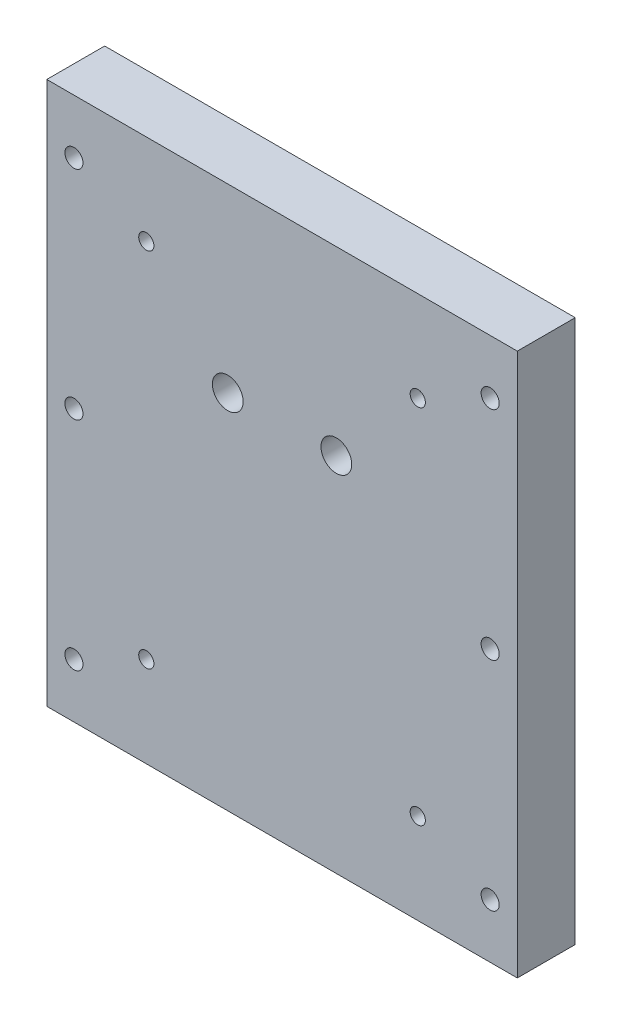
from build123d import *

# Parameters (mm, degrees)
SKETCH1_W              = 130
SKETCH1_H              = 150
EXTRUDE1_DEPTH         = 16
M6_TAPPED_HOLE1_D      = 5
M5_TAPPED_HOLE1_D      = 4.2
M5_TAPPED_HOLE1_DEPTH  = 16
M10_TAPPED_HOLE1_D     = 8.5
M10_TAPPED_HOLE1_DEPTH = 27.5
M10_TAPPED_HOLE1_TIP   = 2.553657631
M10_TAPPED_HOLE2_D     = 8.5
M10_TAPPED_HOLE2_DEPTH = 27.5
M10_TAPPED_HOLE2_TIP   = 2.553657631


with BuildPart() as part:
    # Sketch1 → Extrude1 (new body)
    with BuildSketch(Plane.XY):
        Rectangle(SKETCH1_W, SKETCH1_H)
    extrude(amount=EXTRUDE1_DEPTH)

    # M6 Tapped Hole1 (through all)
    with Locations(Plane.XY.offset(16)):
        with Locations((-57.5, 60), (-57.5, 0), (-57.5, -60), (57.5, -60), (57.5, 0), (57.5, 60)):
            Hole(M6_TAPPED_HOLE1_D / 2)

    # M5 Tapped Hole1
    with Locations(Plane.XY.offset(16)):
        with Locations((-37.5, 50), (37.5, 50), (37.5, -50), (-37.5, -50)):
            Hole(M5_TAPPED_HOLE1_D / 2, depth=M5_TAPPED_HOLE1_DEPTH)

    # M10 Tapped Hole1
    with Locations(Plane(origin=(0, 0, 0), x_dir=(-1, 0, 0), z_dir=(0, 0, -1))):
        with Locations((-15, 25)):
            Hole(M10_TAPPED_HOLE1_D / 2, depth=M10_TAPPED_HOLE1_DEPTH)
            with Locations((0, 0, -(M10_TAPPED_HOLE1_DEPTH + M10_TAPPED_HOLE1_TIP / 2))):  # 118° drill point
                Cone(0, M10_TAPPED_HOLE1_D / 2, M10_TAPPED_HOLE1_TIP, mode=Mode.SUBTRACT)

    # M10 Tapped Hole2
    with Locations(Plane(origin=(0, 0, 0), x_dir=(-1, 0, 0), z_dir=(0, 0, -1))):
        with Locations((15, 25)):
            Hole(M10_TAPPED_HOLE2_D / 2, depth=M10_TAPPED_HOLE2_DEPTH)
            with Locations((0, 0, -(M10_TAPPED_HOLE2_DEPTH + M10_TAPPED_HOLE2_TIP / 2))):  # 118° drill point
                Cone(0, M10_TAPPED_HOLE2_D / 2, M10_TAPPED_HOLE2_TIP, mode=Mode.SUBTRACT)


solid = part.part
